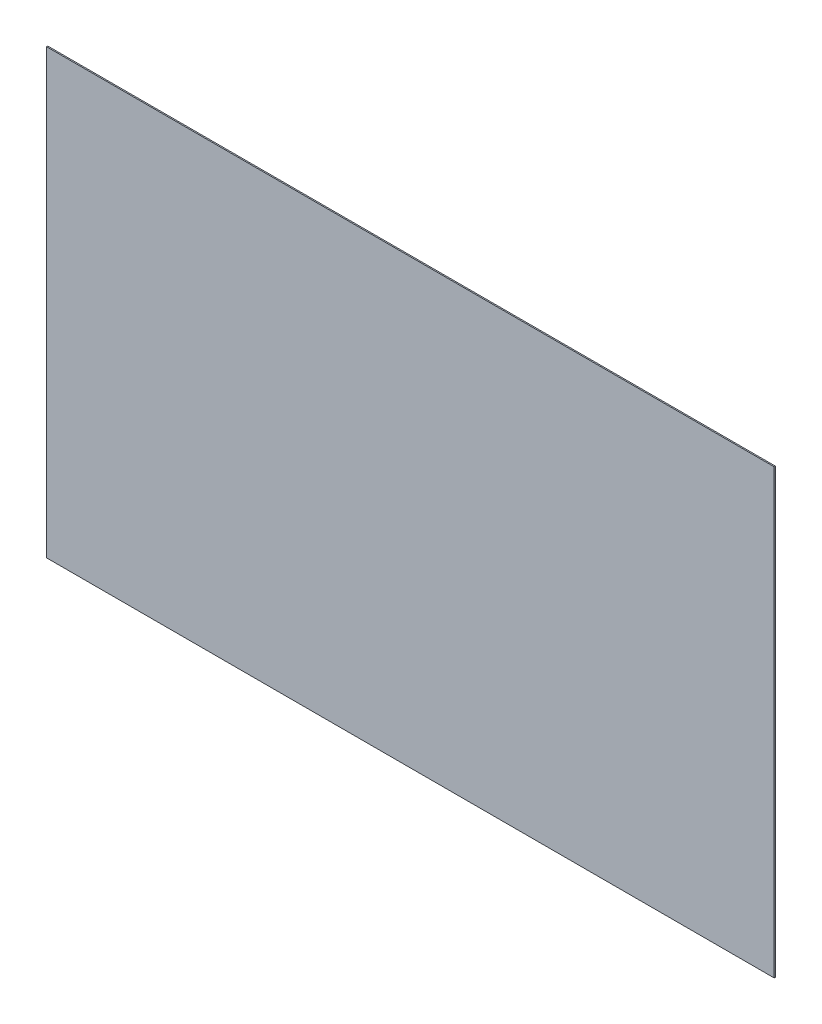
from build123d import *

# Parameters (mm, degrees)
CROQUIS1_W              = 6000
CROQUIS1_H              = 3650
SALIENTE_EXTRUIR1_DEPTH = 10


with BuildPart() as part:
    # Croquis1 → Saliente-Extruir1 (new body)
    with BuildSketch(Plane.XY):
        Rectangle(CROQUIS1_W, CROQUIS1_H)
    extrude(amount=SALIENTE_EXTRUIR1_DEPTH)


solid = part.part
